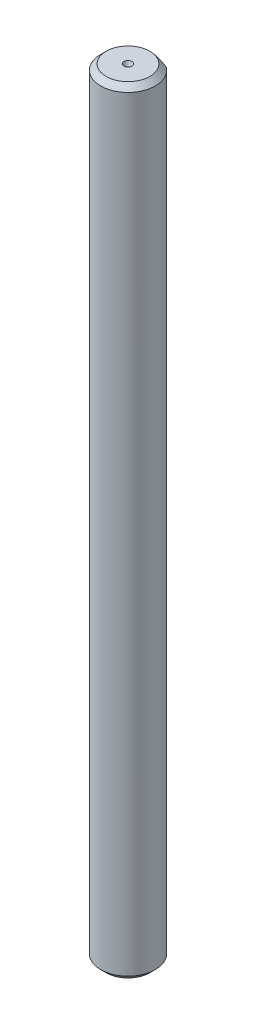
from build123d import *

# Parameters (mm, degrees)
SKETCH_1_R          = 2.5
EXTRUDE_1_DEPTH     = 71
CHAMFER_1_SIZE      = 0.5
CUT_EXTRUDE_START   = -15
CUT_EXTRUDE_2_DEPTH = 15


with BuildPart() as part:
    # Эскиз1 → Бобышка-Вытянуть1 (new body)
    with BuildSketch(Plane(origin=(0, 0, 0), x_dir=(1, 0, 0), z_dir=(0, 1, 0))):
        with Locations(Location((0, 0, 0), (0, 0, 270))):
            Circle(SKETCH_1_R)
    extrude(amount=EXTRUDE_1_DEPTH)

    # Фаска1
    chamfer_1_edges = [part.edges().sort_by_distance(p)[0] for p in [
        (0, 0, -2.5),
        (0, 71, -2.5),
    ]]
    chamfer(chamfer_1_edges, length=CHAMFER_1_SIZE)

    # Вырез-Вытянуть1 cone 1 section (through the dimple's axis) → Вырез-Вытянуть1 (revolve, cut)
    with BuildSketch(Plane(origin=(0, 71, 0), x_dir=(0, 0, 1), z_dir=(1, 0, 0))):
        Polygon((0, 0), (0.368933835, 0), (0, 0.913143285), align=None)
    revolve(axis=Axis((0, 71, 0), (0, -1, 0)), mode=Mode.SUBTRACT)

    # Эскиз3 → Вырез-Вытянуть2 (cut)
    with BuildSketch(Plane(origin=(0, 71, 0), x_dir=(1, 0, 0), z_dir=(0, 1, 0)).offset(CUT_EXTRUDE_START)):
        with BuildLine():
            Line((-1.5, 2), (1.5, 2))
            ThreePointArc((1.5, 2), (0, 2.5), (-1.5, 2))
        make_face()
    extrude(amount=CUT_EXTRUDE_2_DEPTH, mode=Mode.SUBTRACT)


solid = part.part
